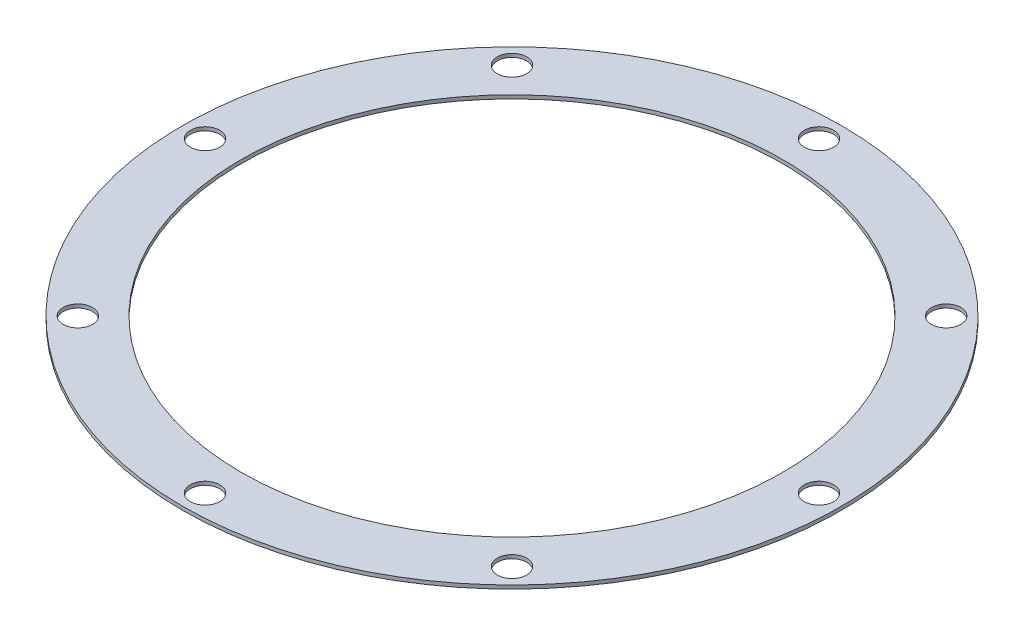
from build123d import *

# Parameters (mm, degrees)
SKETCH1_R           = 73
SKETCH1_R_2         = 60
SKETCH1_R_3         = 3.25
BOSS_EXTRUDE1_DEPTH = 0.79375


with BuildPart() as part:
    # Sketch1 → Boss-Extrude1 (new body)
    with BuildSketch(Plane(origin=(0, 0, 0), x_dir=(1, 0, 0), z_dir=(0, 1, 0))):
        Circle(SKETCH1_R)
        Circle(SKETCH1_R_2, mode=Mode.SUBTRACT)
        with Locations((-48.083261121, 48.083261121)):
            Circle(SKETCH1_R_3, mode=Mode.SUBTRACT)
        with Locations((-68, 0)):
            Circle(SKETCH1_R_3, mode=Mode.SUBTRACT)
        with Locations((0, 68)):
            Circle(SKETCH1_R_3, mode=Mode.SUBTRACT)
        with Locations((48.083261121, 48.083261121)):
            Circle(SKETCH1_R_3, mode=Mode.SUBTRACT)
        with Locations((68, 0)):
            Circle(SKETCH1_R_3, mode=Mode.SUBTRACT)
        with Locations((48.083261121, -48.083261121)):
            Circle(SKETCH1_R_3, mode=Mode.SUBTRACT)
        with Locations((0, -68)):
            Circle(SKETCH1_R_3, mode=Mode.SUBTRACT)
        with Locations((-48.083261121, -48.083261121)):
            Circle(SKETCH1_R_3, mode=Mode.SUBTRACT)
    extrude(amount=BOSS_EXTRUDE1_DEPTH)


solid = part.part
